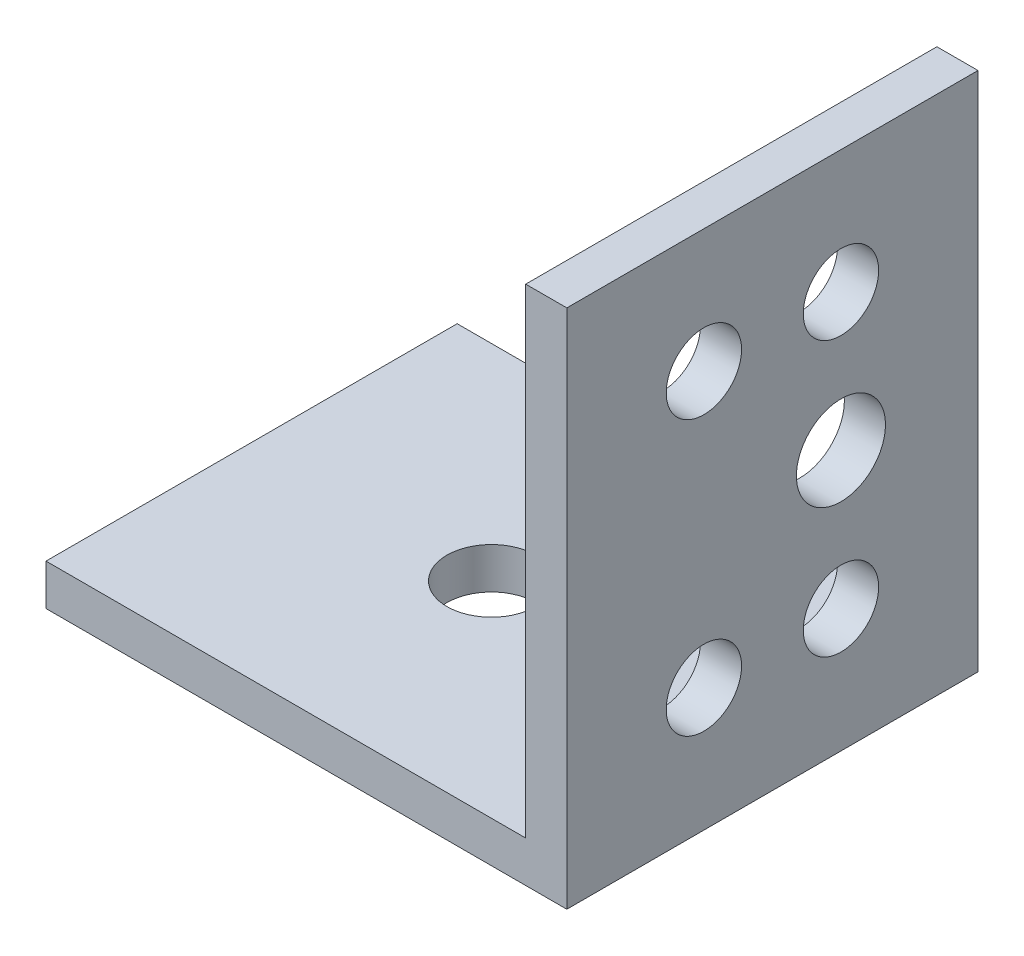
from build123d import *

# Parameters (mm, degrees)
EXTRUDE_1_DEPTH     = 30
CUT_EXTRUDE_3_REACH = 40
SKETCH_4_R          = 2.75
SKETCH_4_R_2        = 3.25
CUT_EXTRUDE_4_REACH = 5
SKETCH_5_R          = 3.25


with BuildPart() as part:
    # 草图1 → 凸台-拉伸1 (new body)
    with BuildSketch(Plane.XY):
        Polygon((0, 0), (0, 38), (-3, 38), (-3, 3), (-38, 3), (-38, 0), align=None)
    extrude(amount=EXTRUDE_1_DEPTH)

    # 草图4 → 切除-拉伸3 (cut, up to next)
    with BuildSketch(Plane(origin=(0, 0, 0), x_dir=(0, 0, -1), z_dir=(1, 0, 0)), mode=Mode.PRIVATE) as cut_extrude_3_sk1:
        with Locations((-10, 29)):
            Circle(SKETCH_4_R)
    cut_extrude_3_tool1 = extrude(cut_extrude_3_sk1.sketch, amount=-CUT_EXTRUDE_3_REACH, mode=Mode.PRIVATE) & part.part
    add(cut_extrude_3_tool1.solids().sort_by_distance((0, 29, 10))[0], mode=Mode.SUBTRACT)
    # 草图4 → 切除-拉伸3 (cut, up to next)
    with BuildSketch(Plane(origin=(0, 0, 0), x_dir=(0, 0, -1), z_dir=(1, 0, 0)), mode=Mode.PRIVATE) as cut_extrude_3_sk2:
        with Locations((-10, 19)):
            Circle(SKETCH_4_R_2)
    cut_extrude_3_tool2 = extrude(cut_extrude_3_sk2.sketch, amount=-CUT_EXTRUDE_3_REACH, mode=Mode.PRIVATE) & part.part
    add(cut_extrude_3_tool2.solids().sort_by_distance((0, 19, 10))[0], mode=Mode.SUBTRACT)
    # 草图4 → 切除-拉伸3 (cut, up to next)
    with BuildSketch(Plane(origin=(0, 0, 0), x_dir=(0, 0, -1), z_dir=(1, 0, 0)), mode=Mode.PRIVATE) as cut_extrude_3_sk3:
        with Locations((-10, 9)):
            Circle(SKETCH_4_R)
    cut_extrude_3_tool3 = extrude(cut_extrude_3_sk3.sketch, amount=-CUT_EXTRUDE_3_REACH, mode=Mode.PRIVATE) & part.part
    add(cut_extrude_3_tool3.solids().sort_by_distance((0, 9, 10))[0], mode=Mode.SUBTRACT)
    # 草图4 → 切除-拉伸3 (cut, up to next)
    with BuildSketch(Plane(origin=(0, 0, 0), x_dir=(0, 0, -1), z_dir=(1, 0, 0)), mode=Mode.PRIVATE) as cut_extrude_3_sk4:
        with Locations((-20, 29)):
            Circle(SKETCH_4_R)
    cut_extrude_3_tool4 = extrude(cut_extrude_3_sk4.sketch, amount=-CUT_EXTRUDE_3_REACH, mode=Mode.PRIVATE) & part.part
    add(cut_extrude_3_tool4.solids().sort_by_distance((0, 29, 20))[0], mode=Mode.SUBTRACT)
    # 草图4 → 切除-拉伸3 (cut, up to next)
    with BuildSketch(Plane(origin=(0, 0, 0), x_dir=(0, 0, -1), z_dir=(1, 0, 0)), mode=Mode.PRIVATE) as cut_extrude_3_sk5:
        with Locations((-20, 9)):
            Circle(SKETCH_4_R)
    cut_extrude_3_tool5 = extrude(cut_extrude_3_sk5.sketch, amount=-CUT_EXTRUDE_3_REACH, mode=Mode.PRIVATE) & part.part
    add(cut_extrude_3_tool5.solids().sort_by_distance((0, 9, 20))[0], mode=Mode.SUBTRACT)

    # 草图5 → 切除-拉伸4 (cut, up to next)
    with BuildSketch(Plane(origin=(0, 3, 0), x_dir=(1, 0, 0), z_dir=(0, 1, 0)), mode=Mode.PRIVATE) as cut_extrude_4_sk1:
        with Locations((-20.5, -15)):
            Circle(SKETCH_5_R)
    cut_extrude_4_tool1 = extrude(cut_extrude_4_sk1.sketch, amount=-CUT_EXTRUDE_4_REACH, mode=Mode.PRIVATE) & part.part
    add(cut_extrude_4_tool1.solids().sort_by_distance((-20.5, 3, 15))[0], mode=Mode.SUBTRACT)


solid = part.part
